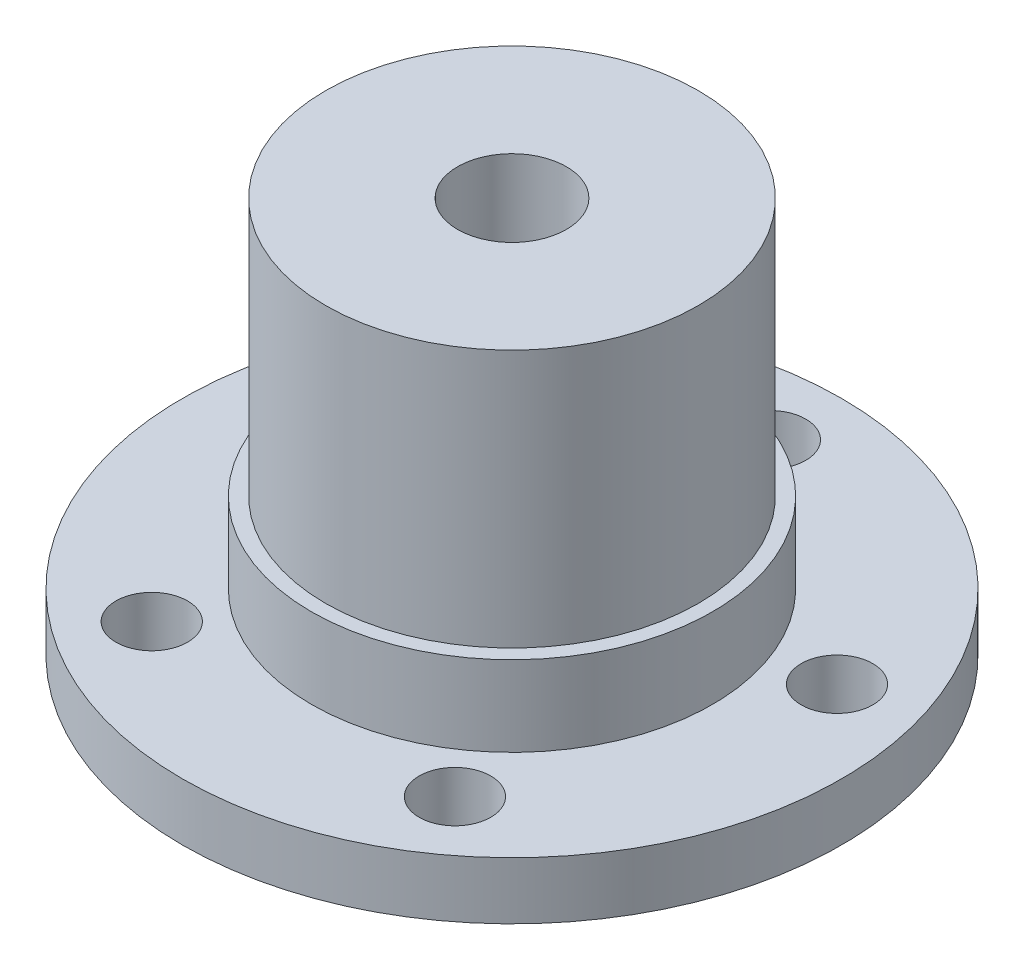
from build123d import *

# Parameters (mm, degrees)
M3X0_5_TAPPED_HOLE1_D      = 2.5
F_10_24_TAPPED_HOLE1_D     = 3.7973
F_10_24_TAPPED_HOLE1_DEPTH = 12.7
F_10_24_TAPPED_HOLE1_TIP   = 1.140824014


with BuildPart() as part:
    # Sketch1 → Revolve1 (revolve)
    with BuildSketch(Plane.XY):
        Polygon((0, 13.8025), (6.5, 13.8025), (6.5, 4.8), (7, 4.8), (7, 2), (11.5, 2), (11.5, 0), (0, 0), align=None)
    revolve(axis=Axis((0, 0, 0), (0, 1, 0)))

    # M3x0.5 Tapped Hole1 (through all)
    with Locations(Plane(origin=(0, 0, 0), x_dir=(-1, 0, 0), z_dir=(0, -1, 0))):
        with Locations((0, 9), (8.559508647, 2.781152949), (5.290067271, -7.281152949), (-5.290067271, -7.281152949), (-8.559508647, 2.781152949), (0, 0)):
            Hole(M3X0_5_TAPPED_HOLE1_D / 2)

    # #10-24 Tapped Hole1
    with Locations(Plane(origin=(0, 13.8025, 0), x_dir=(1, 0, 0), z_dir=(0, 1, 0))):
        with Locations((0, 0)):
            Hole(F_10_24_TAPPED_HOLE1_D / 2, depth=F_10_24_TAPPED_HOLE1_DEPTH)
            with Locations((0, 0, -(F_10_24_TAPPED_HOLE1_DEPTH + F_10_24_TAPPED_HOLE1_TIP / 2))):  # 118° drill point
                Cone(0, F_10_24_TAPPED_HOLE1_D / 2, F_10_24_TAPPED_HOLE1_TIP, mode=Mode.SUBTRACT)


solid = part.part
